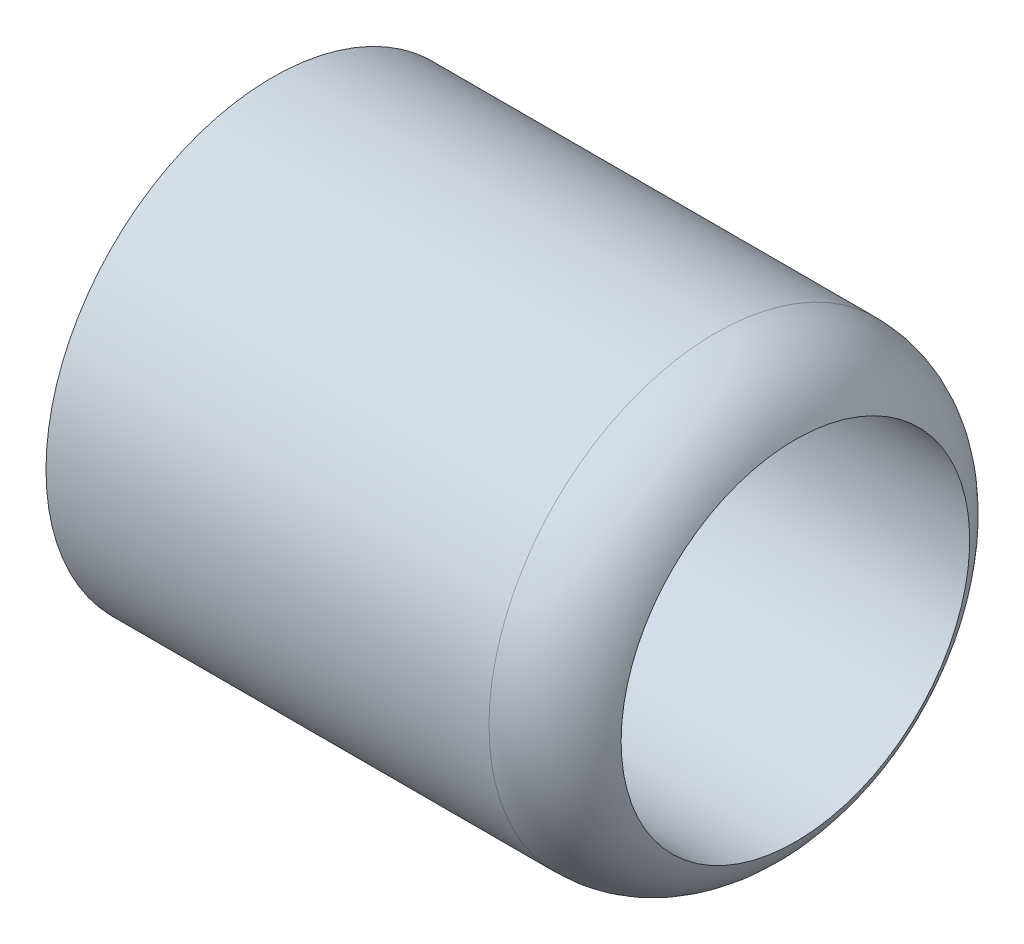
from build123d import *

# Parameters (mm, degrees)
CHAMFER1_SIZE = 1.524


with BuildPart() as part:
    # Sketch1 → Revolve1 (revolve)
    with BuildSketch(Plane.XY):
        with BuildLine():
            Line((0, 0), (12.7, 0))
            Line((12.7, 0), (12.7, -4.572))
            Line((12.7, -4.572), (19.05, -4.572))
            Line((19.05, -4.572), (19.05, 0))
            Line((19.05, 0), (38.1, 0))
            ThreePointArc((38.1, 0), (35.758167108, 2.772791168), (32.280128867, 3.81))
            Line((32.280128867, 3.81), (0, 3.81))
            Line((0, 3.81), (0, 0))
        make_face()
    revolve(axis=Axis((-29.818959813, -12.7, 0), (1, 0, 0)))

    # Chamfer1
    chamfer1_edges = [part.edges().sort_by_distance(p)[0] for p in [
        (0, -25.4, 0),
    ]]
    chamfer(chamfer1_edges, length=CHAMFER1_SIZE)


solid = part.part
